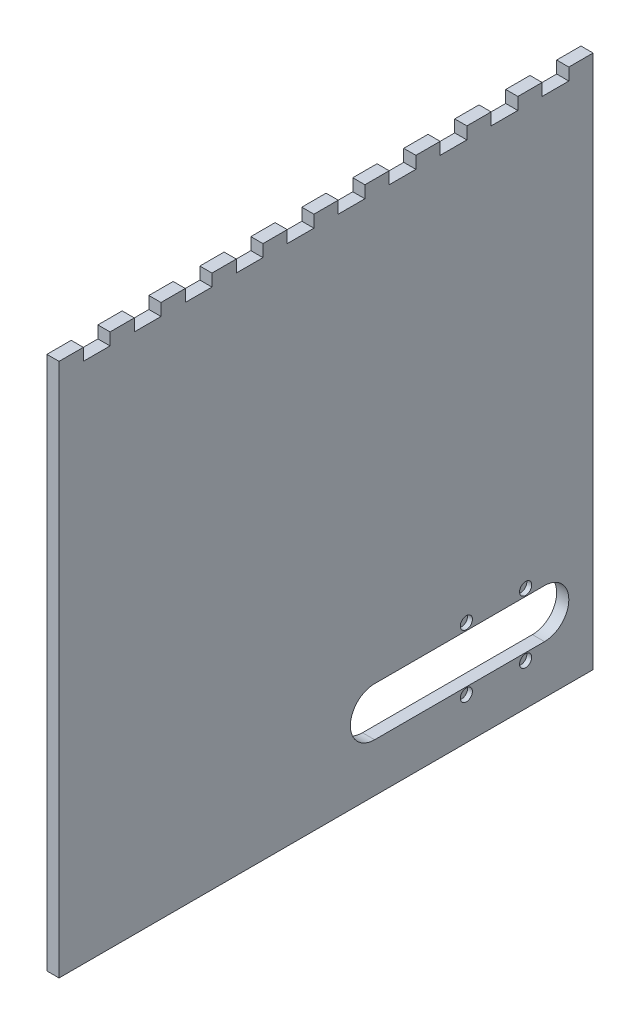
from build123d import *

# Parameters (mm, degrees)
SKETCH1_W           = 279.4
SKETCH1_H           = 285.75
BOSS_EXTRUDE1_DEPTH = 6.35
SKETCH2_W           = 279.4
SKETCH2_H           = 6.35
BOSS_EXTRUDE2_DEPTH = 12.7
CUT_EXTRUDE1_DEPTH  = 20.05
SKETCH5_W           = 51.415141408
SKETCH5_H           = 21.159166417
CUT_EXTRUDE2_DEPTH  = 280.4
SKETCH4_W           = 13.97
SKETCH4_H           = 6.35
CUT_EXTRUDE3_DEPTH  = 6.35
CUT_EXTRUDE5_DEPTH  = 2.54
SKETCH7_W           = 279.4
SKETCH7_H           = 6.35
CUT_EXTRUDE6_DEPTH  = 7.35


with BuildPart() as part:
    # Sketch1 → Boss-Extrude1 (new body)
    with BuildSketch(Plane(origin=(0, 0, 0), x_dir=(0, 0, -1), z_dir=(1, 0, 0))):
        Rectangle(SKETCH1_W, SKETCH1_H)
    extrude(amount=BOSS_EXTRUDE1_DEPTH)

    # Sketch2 → Boss-Extrude2 (add)
    with BuildSketch(Plane(origin=(6.35, 0, 0), x_dir=(0, 0, -1), z_dir=(1, 0, 0))):
        with Locations((0, 139.7)):
            Rectangle(SKETCH2_W, SKETCH2_H)
    extrude(amount=BOSS_EXTRUDE2_DEPTH)

    # Sketch3 → Cut-Extrude1 (cut, through all)
    with BuildSketch(Plane.ZY):
        with BuildLine():
            Line((-114.3, -85.725), (-25.4, -85.725))
            ThreePointArc((-25.4, -85.725), (-12.7, -98.425), (-25.4, -111.125))
            Line((-25.4, -111.125), (-114.3, -111.125))
            ThreePointArc((-114.3, -111.125), (-127, -98.425), (-114.3, -85.725))
        make_face()
    extrude(amount=-CUT_EXTRUDE1_DEPTH, mode=Mode.SUBTRACT)

    # Sketch5 → Cut-Extrude2 (cut, through all)
    with BuildSketch(Plane(origin=(0, 0, -139.7), x_dir=(-1, 0, 0), z_dir=(0, 0, -1))):
        with Locations((-32.057570704, 147.104583209)):
            Rectangle(SKETCH5_W, SKETCH5_H)
    extrude(amount=-CUT_EXTRUDE2_DEPTH, mode=Mode.SUBTRACT)

    # Sketch4 → Cut-Extrude3 (cut)
    with BuildSketch(Plane.ZY):
        with Locations((-120.015, 139.7)):
            Rectangle(SKETCH4_W, SKETCH4_H)
        with Locations((-93.345, 139.7)):
            Rectangle(SKETCH4_W, SKETCH4_H)
        with Locations((-66.675, 139.7)):
            Rectangle(SKETCH4_W, SKETCH4_H)
        with Locations((-40.005, 139.7)):
            Rectangle(SKETCH4_W, SKETCH4_H)
        with Locations((-13.335, 139.7)):
            Rectangle(SKETCH4_W, SKETCH4_H)
        with Locations((13.335, 139.7)):
            Rectangle(SKETCH4_W, SKETCH4_H)
        with Locations((40.005, 139.7)):
            Rectangle(SKETCH4_W, SKETCH4_H)
        with Locations((66.675, 139.7)):
            Rectangle(SKETCH4_W, SKETCH4_H)
        with Locations((93.345, 139.7)):
            Rectangle(SKETCH4_W, SKETCH4_H)
        with Locations((120.015, 139.7)):
            Rectangle(SKETCH4_W, SKETCH4_H)
    extrude(amount=-CUT_EXTRUDE3_DEPTH, mode=Mode.SUBTRACT)

    # Sketch6 → Cut-Extrude5 (cut)
    with BuildSketch(Plane(origin=(6.35, 0, 0), x_dir=(0, 0, -1), z_dir=(1, 0, 0))):
        with BuildLine():
            ThreePointArc((76.575, -82.06), (75.64506403, -79.81493597), (73.4, -78.885))
            ThreePointArc((73.4, -78.885), (74.460660172, -79.324339828), (74.9, -80.385))
            Line((74.9, -80.385), (74.9, -84.858325392))
            ThreePointArc((74.9, -84.858325392), (76.124254485, -83.690663209), (76.575, -82.06))
        make_face()
        with BuildLine():
            Line((71.9, -80.385), (71.9, -84.858325392))
            ThreePointArc((71.9, -84.858325392), (73.4, -85.235), (74.9, -84.858325392))
            Line((74.9, -84.858325392), (74.9, -80.385))
            ThreePointArc((74.9, -80.385), (74.460660172, -79.324339828), (73.4, -78.885))
            ThreePointArc((73.4, -78.885), (72.339339828, -79.324339828), (71.9, -80.385))
        make_face()
        with BuildLine():
            ThreePointArc((73.4, -78.885), (70.320608167, -81.286714193), (71.9, -84.858325392))
            Line((71.9, -84.858325392), (71.9, -80.385))
            ThreePointArc((71.9, -80.385), (72.339339828, -79.324339828), (73.4, -78.885))
        make_face()
        with BuildLine():
            Line((102.9, -80.385), (102.9, -84.858325392))
            ThreePointArc((102.9, -84.858325392), (104.4, -85.235), (105.9, -84.858325392))
            Line((105.9, -84.858325392), (105.9, -80.385))
            ThreePointArc((105.9, -80.385), (105.460660172, -79.324339828), (104.4, -78.885))
            ThreePointArc((104.4, -78.885), (103.339339828, -79.324339828), (102.9, -80.385))
        make_face()
        with BuildLine():
            ThreePointArc((104.4, -78.885), (101.320608167, -81.286714193), (102.9, -84.858325392))
            Line((102.9, -84.858325392), (102.9, -80.385))
            ThreePointArc((102.9, -80.385), (103.339339828, -79.324339828), (104.4, -78.885))
        make_face()
        with BuildLine():
            ThreePointArc((107.575, -82.06), (106.64506403, -79.81493597), (104.4, -78.885))
            ThreePointArc((104.4, -78.885), (105.460660172, -79.324339828), (105.9, -80.385))
            Line((105.9, -80.385), (105.9, -84.858325392))
            ThreePointArc((105.9, -84.858325392), (107.124254485, -83.690663209), (107.575, -82.06))
        make_face()
        with BuildLine():
            ThreePointArc((74.9, -116.465), (74.460660172, -117.525660172), (73.4, -117.965))
            ThreePointArc((73.4, -117.965), (75.64506403, -117.03506403), (76.575, -114.79))
            ThreePointArc((76.575, -114.79), (76.124254485, -113.159336791), (74.9, -111.991674608))
            Line((74.9, -111.991674608), (74.9, -116.465))
        make_face()
        with BuildLine():
            Line((71.9, -111.991674608), (71.9, -116.465))
            ThreePointArc((71.9, -116.465), (72.339339828, -117.525660172), (73.4, -117.965))
            ThreePointArc((73.4, -117.965), (74.460660172, -117.525660172), (74.9, -116.465))
            Line((74.9, -116.465), (74.9, -111.991674608))
            ThreePointArc((74.9, -111.991674608), (73.4, -111.615), (71.9, -111.991674608))
        make_face()
        with BuildLine():
            ThreePointArc((73.4, -117.965), (72.339339828, -117.525660172), (71.9, -116.465))
            Line((71.9, -116.465), (71.9, -111.991674608))
            ThreePointArc((71.9, -111.991674608), (70.320608167, -115.563285807), (73.4, -117.965))
        make_face()
        with BuildLine():
            ThreePointArc((104.4, -117.965), (105.460660172, -117.525660172), (105.9, -116.465))
            Line((105.9, -116.465), (105.9, -111.991674608))
            ThreePointArc((105.9, -111.991674608), (104.4, -111.615), (102.9, -111.991674608))
            Line((102.9, -111.991674608), (102.9, -116.465))
            ThreePointArc((102.9, -116.465), (103.339339828, -117.525660172), (104.4, -117.965))
        make_face()
        with BuildLine():
            Line((105.9, -111.991674608), (105.9, -116.465))
            ThreePointArc((105.9, -116.465), (105.460660172, -117.525660172), (104.4, -117.965))
            ThreePointArc((104.4, -117.965), (106.64506403, -117.03506403), (107.575, -114.79))
            ThreePointArc((107.575, -114.79), (107.124254485, -113.159336791), (105.9, -111.991674608))
        make_face()
        with BuildLine():
            ThreePointArc((102.9, -111.991674608), (101.320608167, -115.563285807), (104.4, -117.965))
            ThreePointArc((104.4, -117.965), (103.339339828, -117.525660172), (102.9, -116.465))
            Line((102.9, -116.465), (102.9, -111.991674608))
        make_face()
    extrude(amount=-CUT_EXTRUDE5_DEPTH, mode=Mode.SUBTRACT)

    # Sketch7 → Cut-Extrude6 (cut, through all)
    with BuildSketch(Plane(origin=(6.35, 0, 0), x_dir=(0, 0, -1), z_dir=(1, 0, 0))):
        with Locations((0, -139.7)):
            Rectangle(SKETCH7_W, SKETCH7_H)
    extrude(amount=-CUT_EXTRUDE6_DEPTH, mode=Mode.SUBTRACT)


solid = part.part
